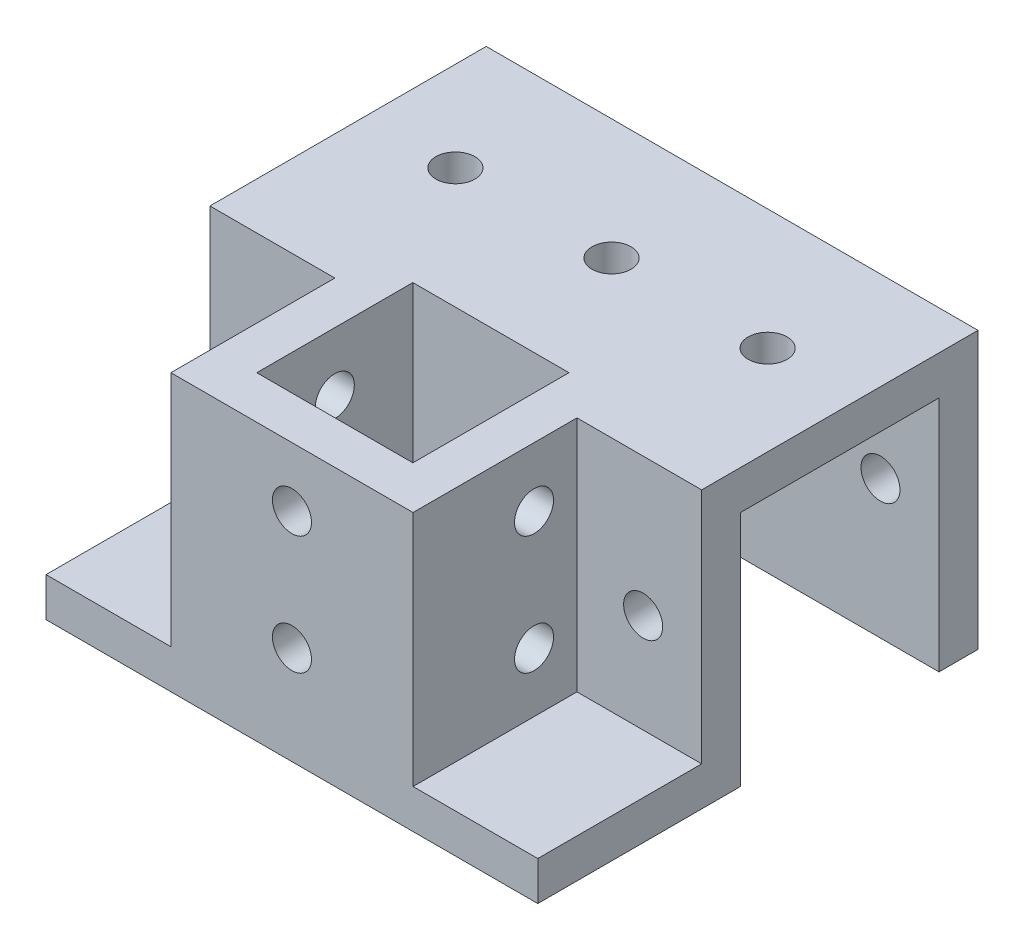
from build123d import *

# Parameters (mm, degrees)
BOSS_EXTRUDE1_DEPTH  = 21
SKETCH4_W            = 42
SKETCH4_H            = 5
BOSS_EXTRUDE2_DEPTH  = 21
SKETCH5_W            = 21
SKETCH5_H            = 5
BOSS_EXTRUDE3_DEPTH  = 5
SKETCH7_W            = 5.022630365
SKETCH7_H            = 30.4
BOSS_EXTRUDE4_DEPTH  = 21
SKETCH8_W            = 26
SKETCH8_H            = 35.4
BOSS_EXTRUDE5_DEPTH  = 5
SKETCH9_W            = 26
SKETCH9_H            = 5
BOSS_EXTRUDE6_DEPTH  = 16
SKETCH10_W           = 16
SKETCH10_H           = 30.4
BOSS_EXTRUDE7_DEPTH  = 5
SKETCH11_W           = 21
SKETCH11_H           = 5
BOSS_EXTRUDE9_DEPTH  = 30.4
SKETCH13_W           = 21
SKETCH13_H           = 4.993745126
BOSS_EXTRUDE10_DEPTH = 30.4
SKETCH15_W           = 30.4
SKETCH15_H           = 5
BOSS_EXTRUDE11_DEPTH = 21
SKETCH18_W           = 5
SKETCH18_H           = 30.4
BOSS_EXTRUDE12_DEPTH = 21
SKETCH19_W           = 4.993745126
SKETCH19_H           = 30.4
BOSS_EXTRUDE13_DEPTH = 21
SKETCH21_W           = 21
SKETCH21_H           = 21
SKETCH21_W_2         = 20
SKETCH21_H_2         = 20
BOSS_EXTRUDE19_DEPTH = 30.4
SKETCH22_R           = 2.5
CUT_EXTRUDE1_DEPTH   = 47.02263
SKETCH24_R           = 2.5
CUT_EXTRUDE2_DEPTH   = 5.5
SKETCH25_R           = 2.5
CUT_EXTRUDE3_DEPTH   = 5
SKETCH26_R           = 2.5
CUT_EXTRUDE4_DEPTH   = 57.4
SKETCH28_W           = 21
SKETCH28_H           = 30.4
CUT_EXTRUDE5_DEPTH   = 0.006255


with BuildPart() as part:
    # Sketch2 → Boss-Extrude1 (new body)
    with BuildSketch(Plane(origin=(0, 0, 0), x_dir=(0, 0, -1), z_dir=(1, 0, 0))):
        Polygon((-17.7, 17.7), (17.7, 17.7), (17.7, -17.7), (12.7, -17.7), (12.7, -12.7), (12.7, 12.7), (-12.7, 12.7), (-12.7, -12.7), (-12.7, -17.7), (-17.7, -17.7), align=None)
    extrude(amount=BOSS_EXTRUDE1_DEPTH)

    # Sketch4 → Boss-Extrude2 (add)
    with BuildSketch(Plane.XY.offset(17.7)):
        with Locations((0, -15.2)):
            Rectangle(SKETCH4_W, SKETCH4_H)
    extrude(amount=BOSS_EXTRUDE2_DEPTH)

    # Sketch5 → Boss-Extrude3 (add)
    with BuildSketch(Plane(origin=(0, 0, 17.7), x_dir=(-1, 0, 0), z_dir=(0, 0, -1))):
        with Locations((10.5, -15.2)):
            Rectangle(SKETCH5_W, SKETCH5_H)
    extrude(amount=BOSS_EXTRUDE3_DEPTH)

    # Sketch7 → Boss-Extrude4 (add)
    with BuildSketch(Plane.XY.offset(17.7)):
        with Locations((2.511315183, 2.5)):
            Rectangle(SKETCH7_W, SKETCH7_H)
    extrude(amount=BOSS_EXTRUDE4_DEPTH)

    # Sketch8 → Boss-Extrude5 (add)
    with BuildSketch(Plane.ZY.offset(21)):
        with Locations((25.7, 0)):
            Rectangle(SKETCH8_W, SKETCH8_H)
    extrude(amount=BOSS_EXTRUDE5_DEPTH)

    # Sketch9 → Boss-Extrude6 (add)
    with BuildSketch(Plane.ZY.offset(26)):
        with Locations((25.7, -15.2)):
            Rectangle(SKETCH9_W, SKETCH9_H)
    extrude(amount=BOSS_EXTRUDE6_DEPTH)

    # Sketch10 → Boss-Extrude7 (add)
    with BuildSketch(Plane(origin=(0, 0, 12.7), x_dir=(-1, 0, 0), z_dir=(0, 0, -1))):
        with Locations((34, 2.5)):
            Rectangle(SKETCH10_W, SKETCH10_H)
    extrude(amount=-BOSS_EXTRUDE7_DEPTH)

    # Sketch11 → Boss-Extrude9 (add)
    with BuildSketch(Plane(origin=(0, 0, 12.7), x_dir=(-1, 0, 0), z_dir=(0, 0, -1))):
        with Locations((31.5, 15.2)):
            Rectangle(SKETCH11_W, SKETCH11_H)
    extrude(amount=BOSS_EXTRUDE9_DEPTH)

    # Sketch13 → Boss-Extrude10 (add)
    with BuildSketch(Plane.XZ.offset(-12.7)):
        with Locations((-31.5, -15.203127437)):
            Rectangle(SKETCH13_W, SKETCH13_H)
    extrude(amount=BOSS_EXTRUDE10_DEPTH)

    # Sketch15 → Boss-Extrude11 (add)
    with BuildSketch(Plane(origin=(-21, 0, 0), x_dir=(0, 0, -1), z_dir=(1, 0, 0))):
        with Locations((2.5, 15.2)):
            Rectangle(SKETCH15_W, SKETCH15_H)
    extrude(amount=BOSS_EXTRUDE11_DEPTH)

    # Sketch18 → Boss-Extrude12 (add)
    with BuildSketch(Plane(origin=(-21, 0, 0), x_dir=(0, 0, -1), z_dir=(1, 0, 0))):
        with Locations((-36.2, 2.5)):
            Rectangle(SKETCH18_W, SKETCH18_H)
    extrude(amount=BOSS_EXTRUDE12_DEPTH)

    # Sketch19 → Boss-Extrude13 (add)
    with BuildSketch(Plane(origin=(-21, 0, 0), x_dir=(0, 0, -1), z_dir=(1, 0, 0))):
        with Locations((15.203127437, -2.5)):
            Rectangle(SKETCH19_W, SKETCH19_H)
    extrude(amount=BOSS_EXTRUDE13_DEPTH)

    # Sketch21 → Boss-Extrude19 (add)
    with BuildSketch(Plane(origin=(0, 17.7, 0), x_dir=(1, 0, 0), z_dir=(0, 1, 0))):
        with Locations((-10.5, -23.2)):
            Rectangle(SKETCH21_W, SKETCH21_H)
        with Locations((-10.5, -23.2)):
            Rectangle(SKETCH21_W_2, SKETCH21_H_2, mode=Mode.SUBTRACT)
    extrude(amount=-BOSS_EXTRUDE19_DEPTH)

    # Sketch22 → Cut-Extrude1 (cut)
    with BuildSketch(Plane(origin=(5.022630365, 0, 0), x_dir=(0, 0, -1), z_dir=(1, 0, 0))):
        with Locations((-23.2, 10.1)):
            Circle(SKETCH22_R)
        with Locations((-23.2, -5.1)):
            Circle(SKETCH22_R)
    extrude(amount=-CUT_EXTRUDE1_DEPTH, mode=Mode.SUBTRACT)

    # Sketch24 → Cut-Extrude2 (cut)
    with BuildSketch(Plane.XY.offset(38.7)):
        with Locations((-10.488684817, 10.1)):
            Circle(SKETCH24_R)
        with Locations((-10.488684817, -5.1)):
            Circle(SKETCH24_R)
    extrude(amount=-CUT_EXTRUDE2_DEPTH, mode=Mode.SUBTRACT)

    # Sketch25 → Cut-Extrude3 (cut)
    with BuildSketch(Plane(origin=(0, 17.7, 0), x_dir=(1, 0, 0), z_dir=(0, 1, 0))):
        with Locations((-10.5, 2.25)):
            Circle(SKETCH25_R)
        with Locations((9.5, 2.25)):
            Circle(SKETCH25_R)
        with Locations((-30.5, 2.25)):
            Circle(SKETCH25_R)
    extrude(amount=-CUT_EXTRUDE3_DEPTH, mode=Mode.SUBTRACT)

    # Sketch26 → Cut-Extrude4 (cut, through all)
    with BuildSketch(Plane(origin=(0, 0, -17.7), x_dir=(-1, 0, 0), z_dir=(0, 0, -1))):
        with Locations((-13.5, 0)):
            Circle(SKETCH26_R)
        with Locations((34.5, 0)):
            Circle(SKETCH26_R)
    extrude(amount=-CUT_EXTRUDE4_DEPTH, mode=Mode.SUBTRACT)

    # Sketch28 → Cut-Extrude5 (cut)
    with BuildSketch(Plane.XY.offset(-12.7)):
        with Locations((10.5, -2.5)):
            Rectangle(SKETCH28_W, SKETCH28_H)
    extrude(amount=-CUT_EXTRUDE5_DEPTH, mode=Mode.SUBTRACT)


solid = part.part
